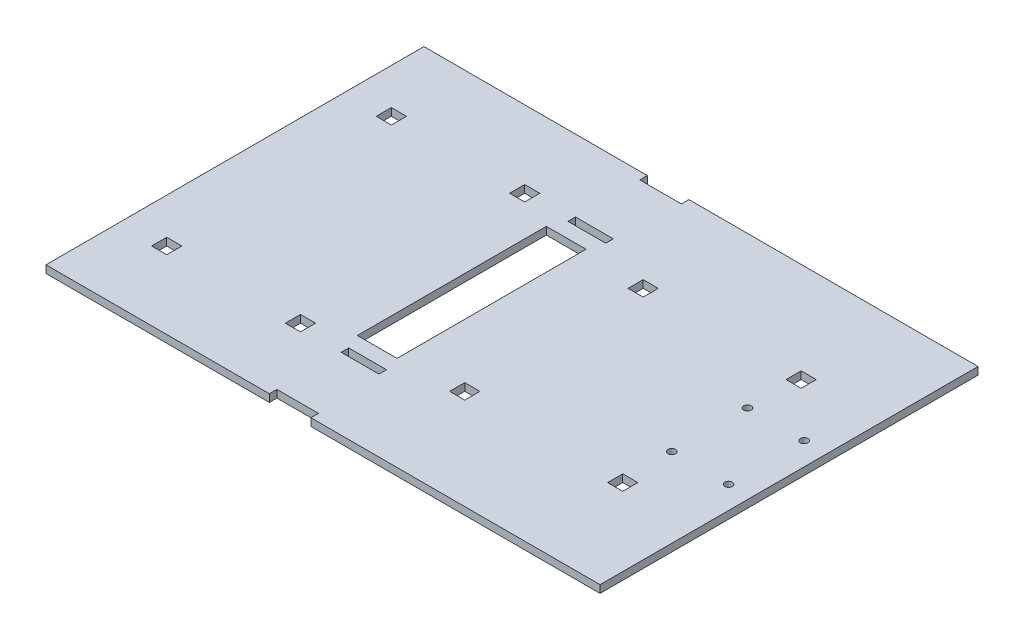
from build123d import *

# Parameters (mm, degrees)
BOSS_EXTRUDE1_DEPTH = 2.54
CUT_EXTRUDE1_REACH  = 4.54
SKETCH2_R           = 1.27
SKETCH2_W           = 5.08
SKETCH2_H           = 5.08
SKETCH2_W_2         = 13.335
SKETCH2_H_2         = 63.5
SKETCH2_W_3         = 12.7
SKETCH2_H_3         = 2.54


with BuildPart() as part:
    # Sketch1 → Boss-Extrude1 (new body)
    with BuildSketch(Plane(origin=(0, 0, 0), x_dir=(1, 0, 0), z_dir=(0, 1, 0))):
        Polygon((-18.034, 63.5), (-18.034, 60.96), (-4.064, 60.96), (-4.064, 63.5), (93.091, 63.5), (93.091, -63.5), (-4.064, -63.5), (-4.064, -60.96), (-18.034, -60.96), (-18.034, -63.5), (-93.091, -63.5), (-93.091, 63.5), align=None)
    extrude(amount=-BOSS_EXTRUDE1_DEPTH)

    # Sketch2 → Cut-Extrude1 (cut, up to next)
    with BuildSketch(Plane(origin=(0, 0, 0), x_dir=(1, 0, 0), z_dir=(0, 1, 0)), mode=Mode.PRIVATE) as cut_extrude1_sk1:
        with Locations((85.471, -12.7)):
            Circle(SKETCH2_R)
    cut_extrude1_tool1 = extrude(cut_extrude1_sk1.sketch, amount=-CUT_EXTRUDE1_REACH, mode=Mode.PRIVATE) & part.part
    add(cut_extrude1_tool1.solids().sort_by_distance((85.471, 0, 12.7))[0], mode=Mode.SUBTRACT)
    # Sketch2 → Cut-Extrude1 (cut, up to next)
    with BuildSketch(Plane(origin=(0, 0, 0), x_dir=(1, 0, 0), z_dir=(0, 1, 0)), mode=Mode.PRIVATE) as cut_extrude1_sk2:
        with Locations((66.421, -12.7)):
            Circle(SKETCH2_R)
    cut_extrude1_tool2 = extrude(cut_extrude1_sk2.sketch, amount=-CUT_EXTRUDE1_REACH, mode=Mode.PRIVATE) & part.part
    add(cut_extrude1_tool2.solids().sort_by_distance((66.421, 0, 12.7))[0], mode=Mode.SUBTRACT)
    # Sketch2 → Cut-Extrude1 (cut, up to next)
    with BuildSketch(Plane(origin=(0, 0, 0), x_dir=(1, 0, 0), z_dir=(0, 1, 0)), mode=Mode.PRIVATE) as cut_extrude1_sk3:
        with Locations((85.471, 12.7)):
            Circle(SKETCH2_R)
    cut_extrude1_tool3 = extrude(cut_extrude1_sk3.sketch, amount=-CUT_EXTRUDE1_REACH, mode=Mode.PRIVATE) & part.part
    add(cut_extrude1_tool3.solids().sort_by_distance((85.471, 0, -12.7))[0], mode=Mode.SUBTRACT)
    # Sketch2 → Cut-Extrude1 (cut, up to next)
    with BuildSketch(Plane(origin=(0, 0, 0), x_dir=(1, 0, 0), z_dir=(0, 1, 0)), mode=Mode.PRIVATE) as cut_extrude1_sk4:
        with Locations((66.421, 12.7)):
            Circle(SKETCH2_R)
    cut_extrude1_tool4 = extrude(cut_extrude1_sk4.sketch, amount=-CUT_EXTRUDE1_REACH, mode=Mode.PRIVATE) & part.part
    add(cut_extrude1_tool4.solids().sort_by_distance((66.421, 0, -12.7))[0], mode=Mode.SUBTRACT)
    # Sketch2 → Cut-Extrude1 (cut, up to next)
    with BuildSketch(Plane(origin=(0, 0, 0), x_dir=(1, 0, 0), z_dir=(0, 1, 0)), mode=Mode.PRIVATE) as cut_extrude1_sk5:
        with Locations((-78.2828, -37.7444)):
            Rectangle(SKETCH2_W, SKETCH2_H)
    cut_extrude1_tool5 = extrude(cut_extrude1_sk5.sketch, amount=-CUT_EXTRUDE1_REACH, mode=Mode.PRIVATE) & part.part
    add(cut_extrude1_tool5.solids().sort_by_distance((-78.2828, 0, 37.7444))[0], mode=Mode.SUBTRACT)
    # Sketch2 → Cut-Extrude1 (cut, up to next)
    with BuildSketch(Plane(origin=(0, 0, 0), x_dir=(1, 0, 0), z_dir=(0, 1, 0)), mode=Mode.PRIVATE) as cut_extrude1_sk6:
        with Locations((-78.2828, 37.7444)):
            Rectangle(SKETCH2_W, SKETCH2_H)
    cut_extrude1_tool6 = extrude(cut_extrude1_sk6.sketch, amount=-CUT_EXTRUDE1_REACH, mode=Mode.PRIVATE) & part.part
    add(cut_extrude1_tool6.solids().sort_by_distance((-78.2828, 0, -37.7444))[0], mode=Mode.SUBTRACT)
    # Sketch2 → Cut-Extrude1 (cut, up to next)
    with BuildSketch(Plane(origin=(0, 0, 0), x_dir=(1, 0, 0), z_dir=(0, 1, 0)), mode=Mode.PRIVATE) as cut_extrude1_sk7:
        with Locations((-13.5509, 0)):
            Rectangle(SKETCH2_W_2, SKETCH2_H_2)
    cut_extrude1_tool7 = extrude(cut_extrude1_sk7.sketch, amount=-CUT_EXTRUDE1_REACH, mode=Mode.PRIVATE) & part.part
    add(cut_extrude1_tool7.solids().sort_by_distance((-13.5509, 0, 0))[0], mode=Mode.SUBTRACT)
    # Sketch2 → Cut-Extrude1 (cut, up to next)
    with BuildSketch(Plane(origin=(0, 0, 0), x_dir=(1, 0, 0), z_dir=(0, 1, 0)), mode=Mode.PRIVATE) as cut_extrude1_sk8:
        with Locations((-11.684, 38.1)):
            Rectangle(SKETCH2_W_3, SKETCH2_H_3)
    cut_extrude1_tool8 = extrude(cut_extrude1_sk8.sketch, amount=-CUT_EXTRUDE1_REACH, mode=Mode.PRIVATE) & part.part
    add(cut_extrude1_tool8.solids().sort_by_distance((-11.684, 0, -38.1))[0], mode=Mode.SUBTRACT)
    # Sketch2 → Cut-Extrude1 (cut, up to next)
    with BuildSketch(Plane(origin=(0, 0, 0), x_dir=(1, 0, 0), z_dir=(0, 1, 0)), mode=Mode.PRIVATE) as cut_extrude1_sk9:
        with Locations((-11.684, -38.1)):
            Rectangle(SKETCH2_W_3, SKETCH2_H_3)
    cut_extrude1_tool9 = extrude(cut_extrude1_sk9.sketch, amount=-CUT_EXTRUDE1_REACH, mode=Mode.PRIVATE) & part.part
    add(cut_extrude1_tool9.solids().sort_by_distance((-11.684, 0, 38.1))[0], mode=Mode.SUBTRACT)
    # Sketch2 → Cut-Extrude1 (cut, up to next)
    with BuildSketch(Plane(origin=(0, 0, 0), x_dir=(1, 0, 0), z_dir=(0, 1, 0)), mode=Mode.PRIVATE) as cut_extrude1_sk10:
        with Locations((67.183, -29.972)):
            Rectangle(SKETCH2_W, SKETCH2_H)
    cut_extrude1_tool10 = extrude(cut_extrude1_sk10.sketch, amount=-CUT_EXTRUDE1_REACH, mode=Mode.PRIVATE) & part.part
    add(cut_extrude1_tool10.solids().sort_by_distance((67.183, 0, 29.972))[0], mode=Mode.SUBTRACT)
    # Sketch2 → Cut-Extrude1 (cut, up to next)
    with BuildSketch(Plane(origin=(0, 0, 0), x_dir=(1, 0, 0), z_dir=(0, 1, 0)), mode=Mode.PRIVATE) as cut_extrude1_sk11:
        with Locations((-33.4772, 37.7444)):
            Rectangle(SKETCH2_W, SKETCH2_H)
    cut_extrude1_tool11 = extrude(cut_extrude1_sk11.sketch, amount=-CUT_EXTRUDE1_REACH, mode=Mode.PRIVATE) & part.part
    add(cut_extrude1_tool11.solids().sort_by_distance((-33.4772, 0, -37.7444))[0], mode=Mode.SUBTRACT)
    # Sketch2 → Cut-Extrude1 (cut, up to next)
    with BuildSketch(Plane(origin=(0, 0, 0), x_dir=(1, 0, 0), z_dir=(0, 1, 0)), mode=Mode.PRIVATE) as cut_extrude1_sk12:
        with Locations((-33.3502, -37.7444)):
            Rectangle(SKETCH2_W, SKETCH2_H)
    cut_extrude1_tool12 = extrude(cut_extrude1_sk12.sketch, amount=-CUT_EXTRUDE1_REACH, mode=Mode.PRIVATE) & part.part
    add(cut_extrude1_tool12.solids().sort_by_distance((-33.3502, 0, 37.7444))[0], mode=Mode.SUBTRACT)
    # Sketch2 → Cut-Extrude1 (cut, up to next)
    with BuildSketch(Plane(origin=(0, 0, 0), x_dir=(1, 0, 0), z_dir=(0, 1, 0)), mode=Mode.PRIVATE) as cut_extrude1_sk13:
        with Locations((67.183, 29.972)):
            Rectangle(SKETCH2_W, SKETCH2_H)
    cut_extrude1_tool13 = extrude(cut_extrude1_sk13.sketch, amount=-CUT_EXTRUDE1_REACH, mode=Mode.PRIVATE) & part.part
    add(cut_extrude1_tool13.solids().sort_by_distance((67.183, 0, -29.972))[0], mode=Mode.SUBTRACT)
    # Sketch2 → Cut-Extrude1 (cut, up to next)
    with BuildSketch(Plane(origin=(0, 0, 0), x_dir=(1, 0, 0), z_dir=(0, 1, 0)), mode=Mode.PRIVATE) as cut_extrude1_sk14:
        with Locations((14.097, 29.972)):
            Rectangle(SKETCH2_W, SKETCH2_H)
    cut_extrude1_tool14 = extrude(cut_extrude1_sk14.sketch, amount=-CUT_EXTRUDE1_REACH, mode=Mode.PRIVATE) & part.part
    add(cut_extrude1_tool14.solids().sort_by_distance((14.097, 0, -29.972))[0], mode=Mode.SUBTRACT)
    # Sketch2 → Cut-Extrude1 (cut, up to next)
    with BuildSketch(Plane(origin=(0, 0, 0), x_dir=(1, 0, 0), z_dir=(0, 1, 0)), mode=Mode.PRIVATE) as cut_extrude1_sk15:
        with Locations((14.097, -29.972)):
            Rectangle(SKETCH2_W, SKETCH2_H)
    cut_extrude1_tool15 = extrude(cut_extrude1_sk15.sketch, amount=-CUT_EXTRUDE1_REACH, mode=Mode.PRIVATE) & part.part
    add(cut_extrude1_tool15.solids().sort_by_distance((14.097, 0, 29.972))[0], mode=Mode.SUBTRACT)


solid = part.part
